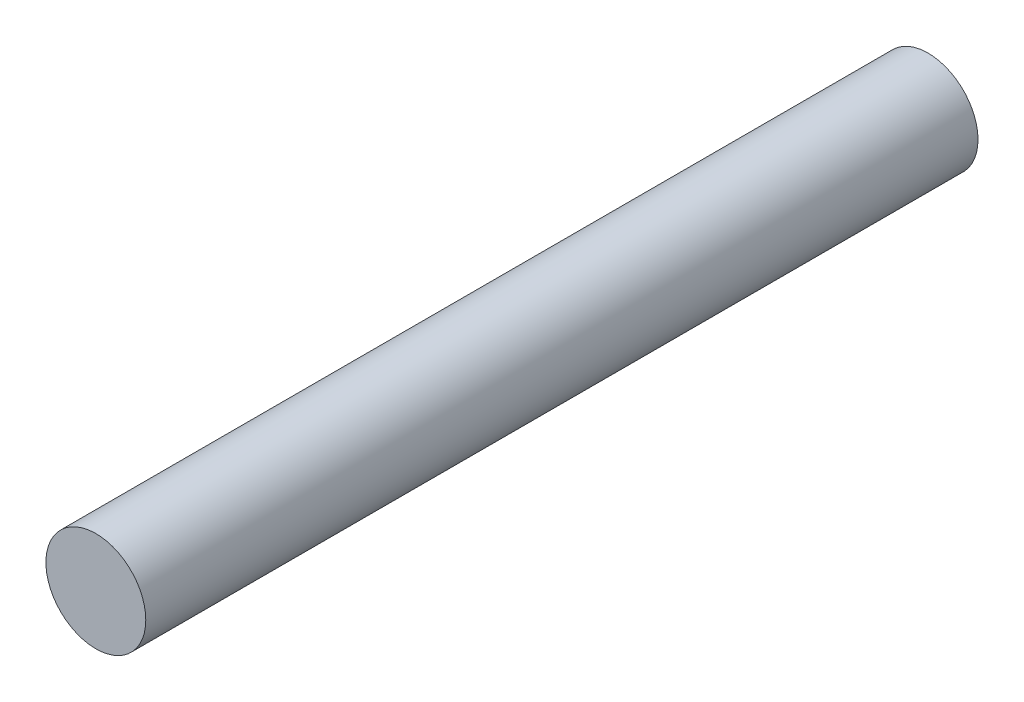
from build123d import *

# Parameters (mm, degrees)
SKETCH_1_R      = 1.5
EXTRUDE_1_DEPTH = 25


with BuildPart() as part:
    # ｽｹｯﾁ1 → ﾎﾞｽ - 押し出し1 (new body)
    with BuildSketch(Plane.XY):
        Circle(SKETCH_1_R)
    extrude(amount=EXTRUDE_1_DEPTH)


solid = part.part
